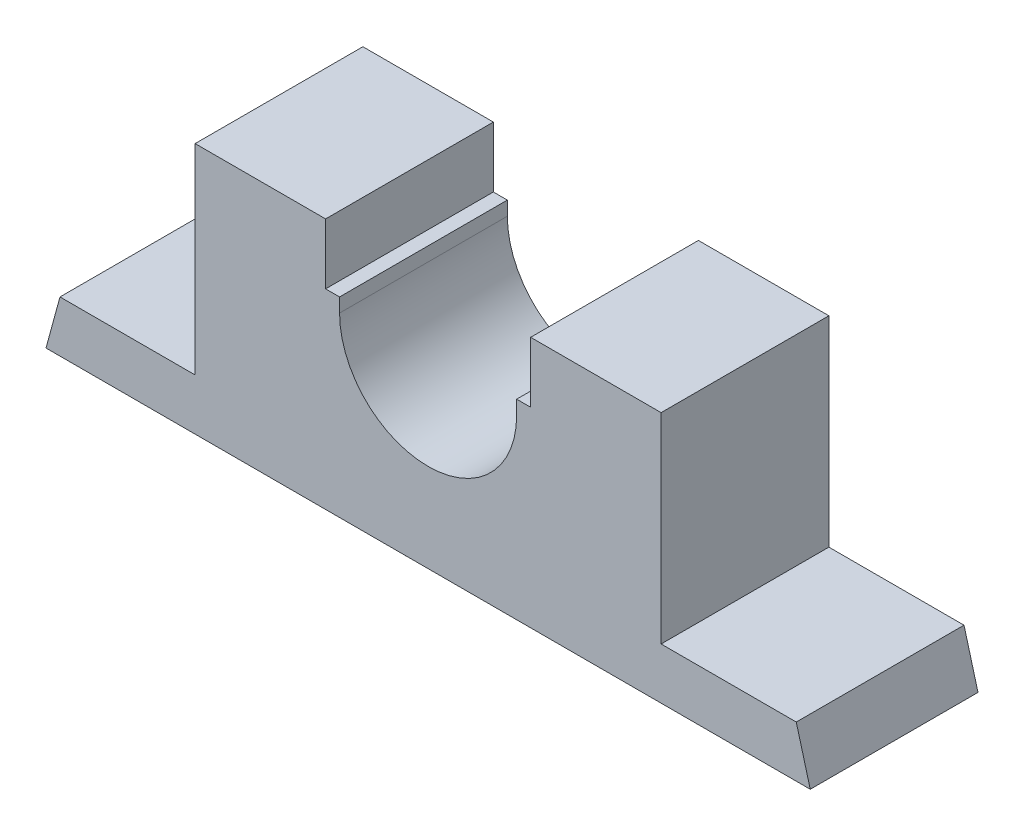
from build123d import *

# Parameters (mm, degrees)
BOSS_EXTRUDE2_DEPTH = 36


with BuildPart() as part:
    # Sketch1 → Boss-Extrude2 (new body)
    with BuildSketch(Plane.XY):
        with BuildLine():
            Line((-82, 0), (82, 0))
            Line((82, 0), (79, 11))
            Line((79, 11), (50, 11))
            Line((50, 11), (50, 54))
            Line((50, 54), (22, 54))
            Line((22, 54), (22, 41))
            Line((22, 41), (19, 41))
            Line((19, 41), (19, 38))
            ThreePointArc((19, 38), (0, 19), (-19, 38))
            Line((-19, 38), (-19, 41))
            Line((-19, 41), (-22, 41))
            Line((-22, 41), (-22, 54))
            Line((-22, 54), (-50, 54))
            Line((-50, 54), (-50, 11))
            Line((-50, 11), (-79, 11))
            Line((-79, 11), (-82, 0))
        make_face()
    extrude(amount=BOSS_EXTRUDE2_DEPTH)


solid = part.part
